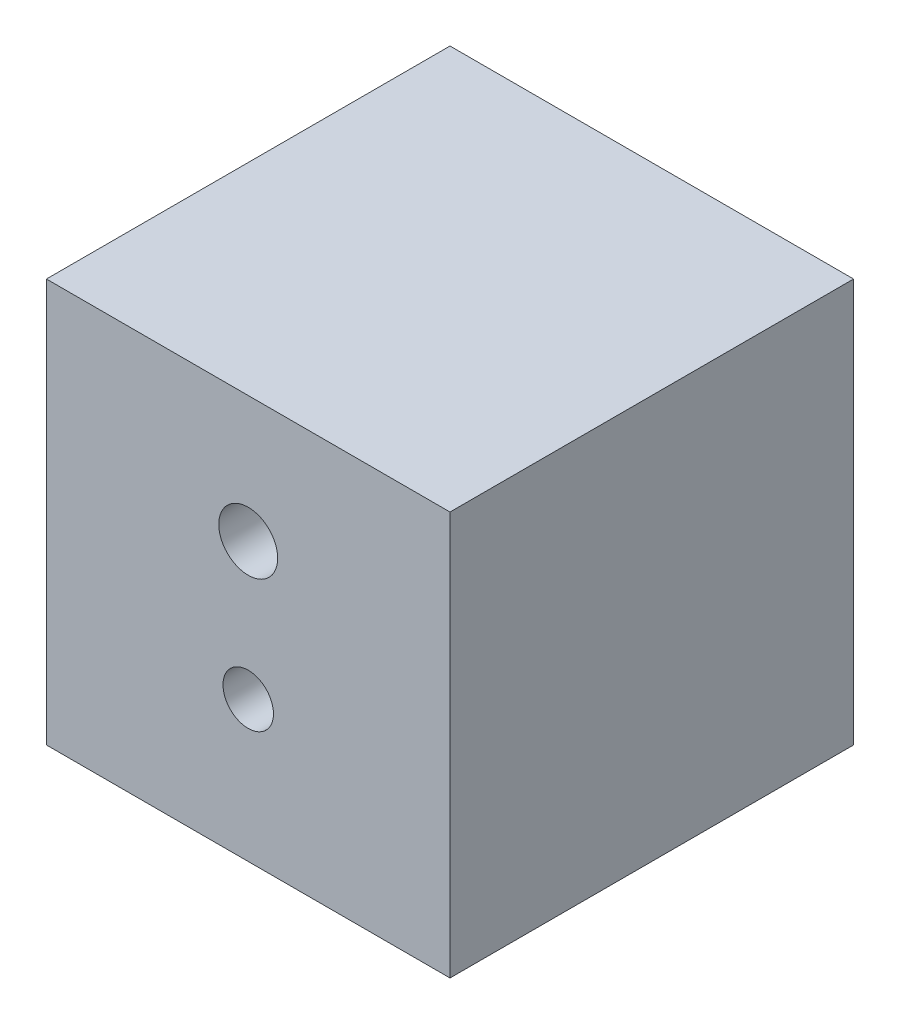
from build123d import *

# Parameters (mm, degrees)
SKETCH2_W           = 76.2
SKETCH2_H           = 76.2
BOSS_EXTRUDE1_DEPTH = 76.2
SKETCH3_R           = 4.7625
SKETCH3_R_2         = 5.5626
CUT_EXTRUDE1_DEPTH  = 72.39
SKETCH5_R           = 5.5626
BOSS_EXTRUDE2_DEPTH = 62.23


with BuildPart() as part:
    # Sketch2 → Boss-Extrude1 (new body)
    with BuildSketch(Plane(origin=(0, 0, 0), x_dir=(1, 0, 0), z_dir=(0, 1, 0))):
        Rectangle(SKETCH2_W, SKETCH2_H)
    extrude(amount=BOSS_EXTRUDE1_DEPTH)

    # Sketch3 → Cut-Extrude1 (cut)
    with BuildSketch(Plane.XY.offset(38.1)):
        with Locations((0, 26.522528218)):
            Circle(SKETCH3_R)
        with Locations((0, 52.367028218)):
            Circle(SKETCH3_R_2)
    extrude(amount=-CUT_EXTRUDE1_DEPTH, mode=Mode.SUBTRACT)

    # Sketch5 → Boss-Extrude2 (add)
    with BuildSketch(Plane.XY.offset(-34.29)):
        with Locations((0, 52.367028218)):
            Circle(SKETCH5_R)
    extrude(amount=BOSS_EXTRUDE2_DEPTH)


solid = part.part
